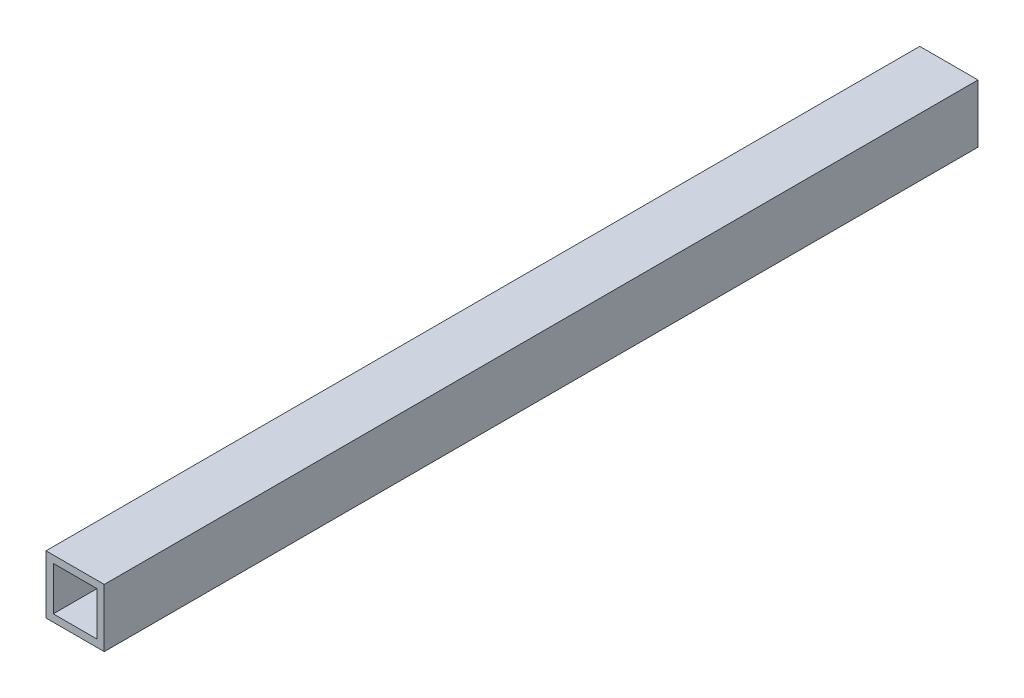
from build123d import *

# Parameters (mm, degrees)
SKETCH1_W           = 203.2
SKETCH1_H           = 203.2
BOSS_EXTRUDE1_DEPTH = 3048
SKETCH3_W           = 152.4
SKETCH3_H           = 152.4
CUT_EXTRUDE1_DEPTH  = 2438.4


with BuildPart() as part:
    # Sketch1 → Boss-Extrude1 (new body)
    with BuildSketch(Plane.XY):
        with Locations((101.6, 101.6)):
            Rectangle(SKETCH1_W, SKETCH1_H)
    extrude(amount=-BOSS_EXTRUDE1_DEPTH)

    # Sketch3 → Cut-Extrude1 (cut)
    with BuildSketch(Plane.XY):
        with Locations((101.6, 101.6)):
            Rectangle(SKETCH3_W, SKETCH3_H)
    extrude(amount=-CUT_EXTRUDE1_DEPTH, mode=Mode.SUBTRACT)


solid = part.part
